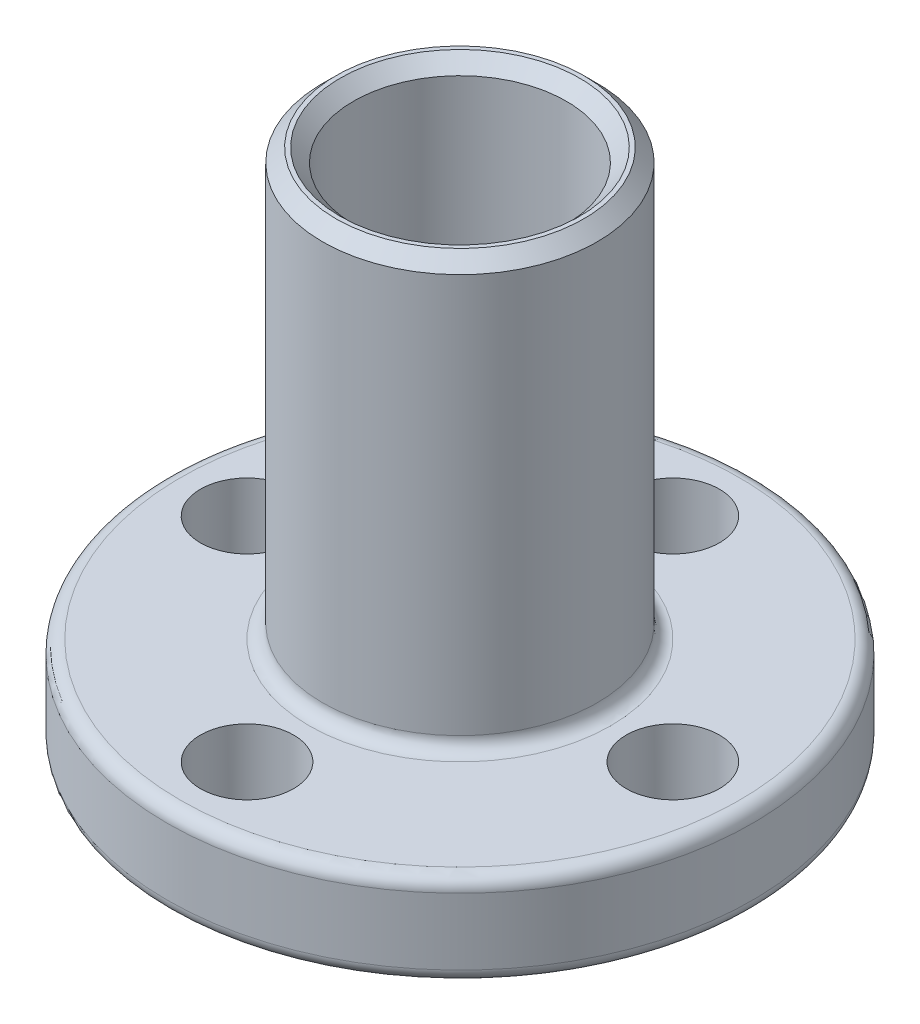
from build123d import *

# Parameters (mm, degrees)
SKETCH1_R           = 5.16
BOSS_EXTRUDE1_DEPTH = 1.5
SKETCH2_R           = 11
BOSS_EXTRUDE2_DEPTH = 3.5
SKETCH3_R           = 5.16
BOSS_EXTRUDE3_DEPTH = 16
SKETCH4_R           = 4
CUT_EXTRUDE1_DEPTH  = 26
SKETCH5_R           = 1.75
CUT_EXTRUDE2_DEPTH  = 26
CIRPATTERN1_COUNT   = 4
FILLET1_R           = 0.5
CHAMFER1_SIZE       = 0.5


with BuildPart() as part:
    # Sketch1 → Boss-Extrude1 (new body)
    with BuildSketch(Plane(origin=(0, 0, 0), x_dir=(1, 0, 0), z_dir=(0, 1, 0))):
        Circle(SKETCH1_R)
    extrude(amount=BOSS_EXTRUDE1_DEPTH)

    # Sketch2 → Boss-Extrude2 (add)
    with BuildSketch(Plane(origin=(0, 1.5, 0), x_dir=(1, 0, 0), z_dir=(0, 1, 0))):
        Circle(SKETCH2_R)
    extrude(amount=BOSS_EXTRUDE2_DEPTH)

    # Sketch3 → Boss-Extrude3 (add)
    with BuildSketch(Plane(origin=(0, 5, 0), x_dir=(1, 0, 0), z_dir=(0, 1, 0))):
        Circle(SKETCH3_R)
    extrude(amount=BOSS_EXTRUDE3_DEPTH)

    # Sketch4 → Cut-Extrude1 (cut)
    with BuildSketch(Plane(origin=(0, 21, 0), x_dir=(1, 0, 0), z_dir=(0, 1, 0))):
        Circle(SKETCH4_R)
    extrude(amount=-CUT_EXTRUDE1_DEPTH, mode=Mode.SUBTRACT)

    # Sketch5 → Cut-Extrude2 (cut)
    with BuildSketch(Plane(origin=(0, 5, 0), x_dir=(1, 0, 0), z_dir=(0, 1, 0))):
        with Locations((0, 8)):
            Circle(SKETCH5_R)
    cut_extrude2 = extrude(amount=-CUT_EXTRUDE2_DEPTH, mode=Mode.SUBTRACT)

    # CirPattern1: Cut-Extrude2 ×4 about axis
    cirpattern1_axis = Axis((0, 0, 0), (0, 1, 0))
    for i in range(1, CIRPATTERN1_COUNT):
        add(cut_extrude2.rotate(cirpattern1_axis, i * 360 / CIRPATTERN1_COUNT), mode=Mode.SUBTRACT)

    # Fillet1
    fillet1_edges = [part.edges().sort_by_distance(p)[0] for p in [
        (-5.16, 1.5, 0),
        (-11, 1.5, 0),
        (-11, 5, 0),
        (-5.16, 5, 0),
    ]]
    fillet(fillet1_edges, radius=FILLET1_R)

    # Chamfer1
    chamfer1_edges = [part.edges().sort_by_distance(p)[0] for p in [
        (-5.16, 21, 0),
        (-4, 0, 0),
        (-4, 21, 0),
        (-5.16, 0, 0),
    ]]
    chamfer(chamfer1_edges, length=CHAMFER1_SIZE)


solid = part.part
